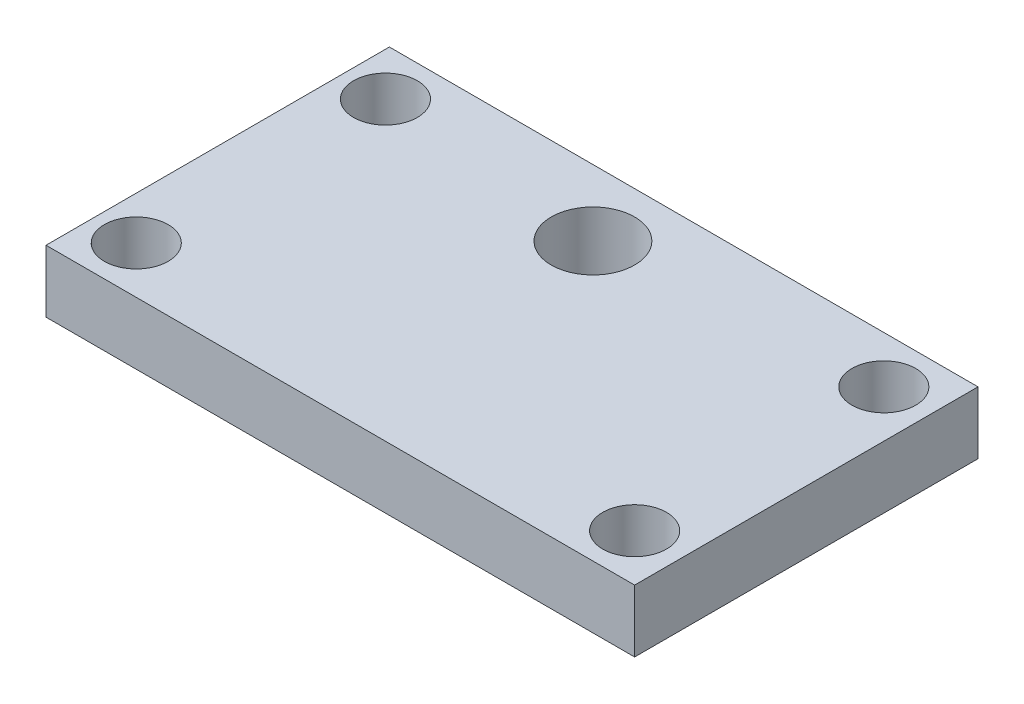
from build123d import *

# Parameters (mm, degrees)
SKETCH1_W           = 60
SKETCH1_H           = 35
SKETCH1_R           = 3.25
BOSS_EXTRUDE1_DEPTH = 6.35
SKETCH2_R           = 4.25
CUT_EXTRUDE1_DEPTH  = 7.35


with BuildPart() as part:
    # Sketch1 → Boss-Extrude1 (new body)
    with BuildSketch(Plane(origin=(0, 0, 0), x_dir=(1, 0, 0), z_dir=(0, 1, 0))):
        Rectangle(SKETCH1_W, SKETCH1_H)
        with Locations((-25.6, 12.7)):
            Circle(SKETCH1_R, mode=Mode.SUBTRACT)
        with Locations((25.2, 12.7)):
            Circle(SKETCH1_R, mode=Mode.SUBTRACT)
        with Locations((-25.6, -12.7)):
            Circle(SKETCH1_R, mode=Mode.SUBTRACT)
        with Locations((25.2, -12.7)):
            Circle(SKETCH1_R, mode=Mode.SUBTRACT)
    extrude(amount=BOSS_EXTRUDE1_DEPTH)

    # Sketch2 → Cut-Extrude1 (cut, through all)
    with BuildSketch(Plane(origin=(0, 6.35, 0), x_dir=(1, 0, 0), z_dir=(0, 1, 0))):
        with Locations((-2.5, 10.75)):
            Circle(SKETCH2_R)
    extrude(amount=-CUT_EXTRUDE1_DEPTH, mode=Mode.SUBTRACT)


solid = part.part
